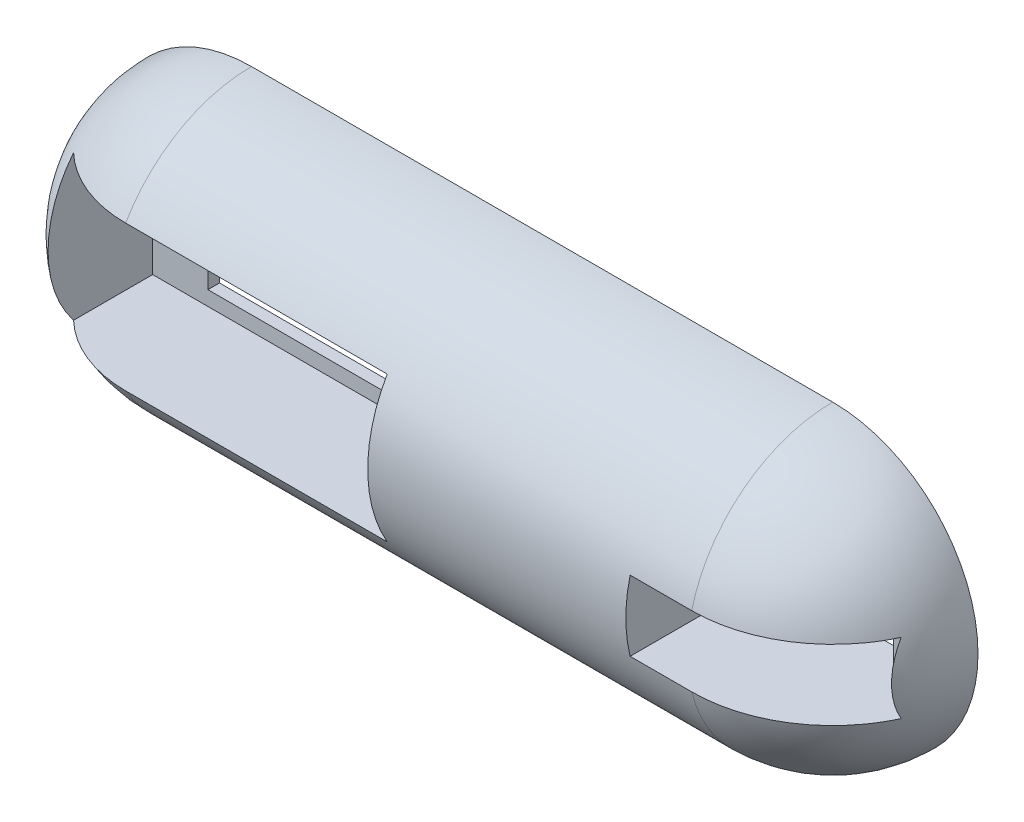
from build123d import *

# Parameters (mm, degrees)
REVOLVE1_ANGLE                  = 180
CUT_EXTRUDE3_START              = -2
SKETCH3_W                       = 60
SKETCH3_H                       = 25
CUT_EXTRUDE3_DEPTH              = 24
SKETCH7_R                       = 2
SKETCH7_W                       = 40
SKETCH7_H                       = 20
SKETCH7_R_2                     = 3
CUT_EXTRUDE8_DEPTH              = 10
CUT_EXTRUDE13_START             = 25
SKETCH16_R                      = 1
SKETCH16_W                      = 23.5
SKETCH16_H                      = 12.1
CUT_EXTRUDE13_DEPTH             = 23
CUT_EXTRUDE14_START             = -7
SKETCH18_W                      = 4.55
SKETCH18_H                      = 12.1
CUT_EXTRUDE14_DEPTH             = 19.0000001
SKETCH19_R                      = 2.5
CUT_EXTRUDE15_DEPTH             = 3
SKIZZE1_R                       = 4.489769008
SCHNITT_LINEAR_AUSTRAGEN1_DEPTH = 10
SKIZZE2_W                       = 23.5
SKIZZE2_H                       = 12.1
SCHNITT_LINEAR_AUSTRAGEN2_DEPTH = 10


with BuildPart() as part:
    # Sketch1 → Revolve1 (revolve)
    with BuildSketch(Plane.XY):
        with BuildLine():
            Line((-125, 0), (25, 0))
            ThreePointArc((25, 0), (17.67766953, 17.67766953), (0, 25))
            Line((0, 25), (-100, 25))
            ThreePointArc((-100, 25), (-117.67766953, 17.67766953), (-125, 0))
        make_face()
    revolve(axis=Axis((-125, 0, 0), (1, 0, 0)), revolution_arc=REVOLVE1_ANGLE)

    # Sketch3 → Cut-Extrude3 (cut, through all)
    with BuildSketch(Plane(origin=(0, 0, 0), x_dir=(-1, 0, 0), z_dir=(0, 0, -1)).offset(CUT_EXTRUDE3_START)):
        with Locations((85, 0)):
            Rectangle(SKETCH3_W, SKETCH3_H)
    extrude(amount=-CUT_EXTRUDE3_DEPTH, mode=Mode.SUBTRACT)

    # Sketch7 → Cut-Extrude8 (cut)
    with BuildSketch(Plane.XY.offset(2)):
        with Locations((-109.5, 5)):
            Circle(SKETCH7_R)
        with Locations((-61.5, 5)):
            Circle(SKETCH7_R)
        with Locations((-109.5, -5)):
            Circle(SKETCH7_R)
        with Locations((-61.5, -5)):
            Circle(SKETCH7_R)
        with Locations((-85.5, 0)):
            Rectangle(SKETCH7_W, SKETCH7_H)
        with Locations((-95.5, -0.25)):
            Circle(SKETCH7_R_2, mode=Mode.SUBTRACT)
    extrude(amount=-CUT_EXTRUDE8_DEPTH, mode=Mode.SUBTRACT)

    # Sketch16 → Cut-Extrude13 (cut)
    with BuildSketch(Plane.XY.offset(CUT_EXTRUDE13_START)):
        with Locations((-8.55, 0)):
            Circle(SKETCH16_R)
        with Locations((19.95, 0)):
            Circle(SKETCH16_R)
        with Locations((5.7, 0)):
            Rectangle(SKETCH16_W, SKETCH16_H)
    extrude(amount=-CUT_EXTRUDE13_DEPTH, mode=Mode.SUBTRACT)

    # Sketch18 → Cut-Extrude14 (cut, through all)
    with BuildSketch(Plane(origin=(0, 0, 0), x_dir=(-1, 0, 0), z_dir=(0, 0, -1)).offset(CUT_EXTRUDE14_START)):
        with Locations((-19.725, 0)):
            Rectangle(SKETCH18_W, SKETCH18_H)
        with Locations((8.325, 0)):
            Rectangle(SKETCH18_W, SKETCH18_H)
    extrude(amount=-CUT_EXTRUDE14_DEPTH, mode=Mode.SUBTRACT)

    # Sketch19 → Cut-Extrude15 (cut, through all)
    with BuildSketch(Plane.XY.offset(2)):
        with Locations((11, 0)):
            Circle(SKETCH19_R)
    extrude(amount=-CUT_EXTRUDE15_DEPTH, mode=Mode.SUBTRACT)

    # Skizze1 → Schnitt-Linear austragen1 (cut)
    with BuildSketch(Plane.XY.offset(2)):
        with Locations((-95.5, -0.25)):
            Circle(SKIZZE1_R)
    extrude(amount=-SCHNITT_LINEAR_AUSTRAGEN1_DEPTH, mode=Mode.SUBTRACT)

    # Skizze2 → Schnitt-Linear austragen2 (cut)
    with BuildSketch(Plane.XY.offset(2)):
        with Locations((5.7, 0)):
            Rectangle(SKIZZE2_W, SKIZZE2_H)
    extrude(amount=-SCHNITT_LINEAR_AUSTRAGEN2_DEPTH, mode=Mode.SUBTRACT)


solid = part.part
